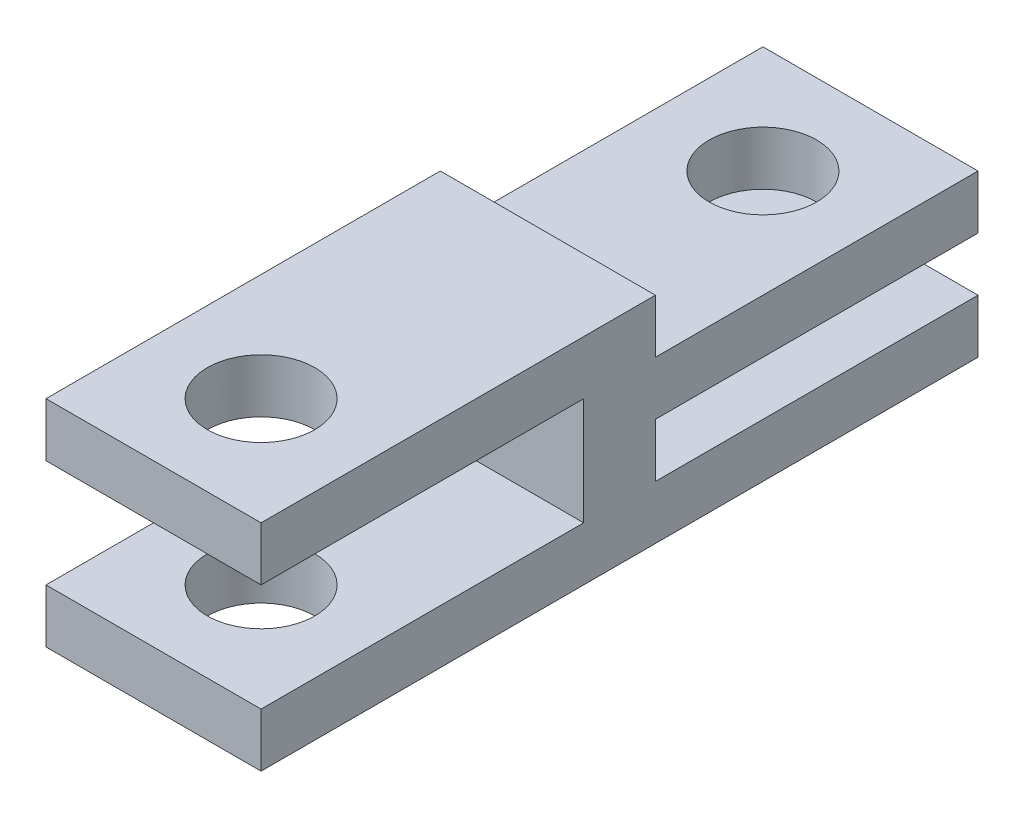
from build123d import *

# Parameters (mm, degrees)
BOSS_EXTRUDE1_DEPTH = 6
SKETCH2_R           = 1.5
CUT_EXTRUDE1_DEPTH  = 6


with BuildPart() as part:
    # Sketch1 → Boss-Extrude1 (new body)
    with BuildSketch(Plane(origin=(0, 0, 0), x_dir=(0, 0, -1), z_dir=(1, 0, 0))):
        Polygon((0, 0), (-20, 0), (-20, 1.5), (-11, 1.5), (-11, 4.5), (-20, 4.5), (-20, 6), (-9, 6), (-9, 4.5), (0, 4.5), (0, 3), (-9, 3), (-9, 1.5), (0, 1.5), align=None)
    extrude(amount=BOSS_EXTRUDE1_DEPTH)

    # Sketch2 → Cut-Extrude1 (cut)
    with BuildSketch(Plane.XZ):
        with Locations((3, 3)):
            Circle(SKETCH2_R)
        with Locations((3, 17)):
            Circle(SKETCH2_R)
    extrude(amount=-CUT_EXTRUDE1_DEPTH, mode=Mode.SUBTRACT)


solid = part.part
